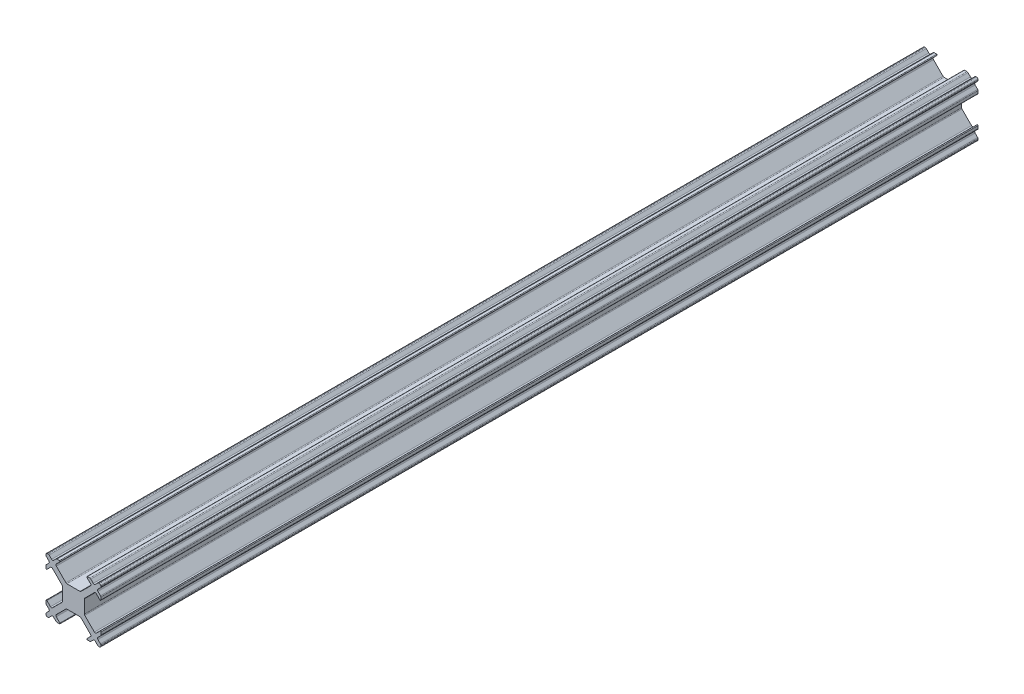
from build123d import *

# Parameters (mm, degrees)
BOSS_EXTRUDE1_DEPTH = 160


with BuildPart() as part:
    # Sketch1 → Boss-Extrude1 (new body)
    with BuildSketch(Plane.XY):
        with BuildLine():
            Line((-26.434620061, 28.496491655), (-25.979594809, 28.951516907))
            ThreePointArc((-25.979594809, 28.951516907), (-25.906371503, 29.128293603), (-25.979594808, 29.305070299))
            Line((-25.979594808, 29.305070299), (-26.43462006, 29.760095551))
            ThreePointArc((-26.43462006, 29.760095551), (-26.488813248, 29.841201388), (-26.507843365, 29.936872247))
            Line((-26.507843365, 29.936872247), (-26.507843365, 30.078293605))
            ThreePointArc((-26.507843365, 30.078293605), (-26.43462006, 30.255070299), (-26.257843366, 30.328293604))
            Line((-26.257843366, 30.328293604), (-26.11642201, 30.328293604))
            ThreePointArc((-26.11642201, 30.328293604), (-26.020751153, 30.309263487), (-25.939645316, 30.255070299))
            Line((-25.939645316, 30.255070299), (-25.484620061, 29.800045045))
            ThreePointArc((-25.484620061, 29.800045045), (-25.307843366, 29.72682174), (-25.131066671, 29.800045045))
            Line((-25.131066671, 29.800045045), (-24.676041418, 30.255070298))
            ThreePointArc((-24.676041418, 30.255070298), (-24.594935581, 30.309263487), (-24.499264722, 30.328293604))
            Line((-24.499264722, 30.328293604), (-24.042157942, 30.328293604))
            ThreePointArc((-24.042157942, 30.328293604), (-23.949769989, 30.266561947), (-23.971447265, 30.157582926))
            Line((-23.971447265, 30.157582926), (-24.623959891, 29.505070299))
            ThreePointArc((-24.623959891, 29.505070299), (-24.697183196, 29.328293604), (-24.623959891, 29.15151691))
            Line((-24.623959891, 29.15151691), (-22.873959891, 27.401516909))
            ThreePointArc((-22.873959891, 27.401516909), (-22.792854054, 27.347323722), (-22.697183196, 27.328293605))
            Line((-22.697183196, 27.328293605), (-20.318503539, 27.328293605))
            ThreePointArc((-20.318503539, 27.328293605), (-20.222832681, 27.347323722), (-20.141726844, 27.401516909))
            Line((-20.141726844, 27.401516909), (-18.391726844, 29.15151691))
            ThreePointArc((-18.391726844, 29.15151691), (-18.318503539, 29.328293604), (-18.391726844, 29.505070299))
            Line((-18.391726844, 29.505070299), (-19.04423947, 30.157582926))
            ThreePointArc((-19.04423947, 30.157582926), (-19.065916745, 30.266561947), (-18.973528793, 30.328293604))
            Line((-18.973528793, 30.328293604), (-18.516422013, 30.328293604))
            ThreePointArc((-18.516422013, 30.328293604), (-18.420751155, 30.309263487), (-18.339645319, 30.2550703))
            Line((-18.339645319, 30.2550703), (-17.884620064, 29.800045045))
            ThreePointArc((-17.884620064, 29.800045045), (-17.707843369, 29.72682174), (-17.531066674, 29.800045045))
            Line((-17.531066674, 29.800045045), (-17.07604142, 30.2550703))
            ThreePointArc((-17.07604142, 30.2550703), (-16.994935583, 30.309263487), (-16.899264725, 30.328293604))
            Line((-16.899264725, 30.328293604), (-16.75784337, 30.328293604))
            ThreePointArc((-16.75784337, 30.328293604), (-16.581066675, 30.255070299), (-16.507843371, 30.078293605))
            Line((-16.507843371, 30.078293605), (-16.507843371, 29.936872247))
            ThreePointArc((-16.507843371, 29.936872247), (-16.526873488, 29.841201389), (-16.581066675, 29.760095552))
            Line((-16.581066675, 29.760095552), (-17.036091927, 29.3050703))
            ThreePointArc((-17.036091927, 29.3050703), (-17.109315232, 29.128293603), (-17.036091926, 28.951516907))
            Line((-17.036091926, 28.951516907), (-16.581066674, 28.496491655))
            ThreePointArc((-16.581066674, 28.496491655), (-16.526873486, 28.415385818), (-16.507843369, 28.31971496))
            Line((-16.507843369, 28.31971496), (-16.507843369, 27.862608178))
            ThreePointArc((-16.507843369, 27.862608178), (-16.569575025, 27.770220231), (-16.678554041, 27.791897499))
            Line((-16.678554041, 27.791897499), (-17.331066668, 28.444410126))
            ThreePointArc((-17.331066668, 28.444410126), (-17.507843364, 28.517633431), (-17.68462006, 28.444410125))
            Line((-17.68462006, 28.444410125), (-19.434620061, 26.694410125))
            ThreePointArc((-19.434620061, 26.694410125), (-19.488813248, 26.613304288), (-19.507843364, 26.51763343))
            Line((-19.507843364, 26.51763343), (-19.507843364, 24.138953775))
            ThreePointArc((-19.507843364, 24.138953775), (-19.488813247, 24.043282917), (-19.434620059, 23.962177079))
            Line((-19.434620059, 23.962177079), (-17.684620059, 22.212177079))
            ThreePointArc((-17.684620059, 22.212177079), (-17.507843363, 22.138953773), (-17.331066666, 22.212177077))
            Line((-17.331066666, 22.212177077), (-16.67855404, 22.864689704))
            ThreePointArc((-16.67855404, 22.864689704), (-16.569575019, 22.886366979), (-16.507843363, 22.793979027))
            Line((-16.507843363, 22.793979027), (-16.507843363, 22.336872245))
            ThreePointArc((-16.507843363, 22.336872245), (-16.52687348, 22.241201387), (-16.581066668, 22.16009555))
            Line((-16.581066668, 22.16009555), (-17.036091921, 21.705070296))
            ThreePointArc((-17.036091921, 21.705070296), (-17.109315225, 21.528293601), (-17.036091921, 21.351516906))
            Line((-17.036091921, 21.351516906), (-16.581066669, 20.896491654))
            ThreePointArc((-16.581066669, 20.896491654), (-16.526873481, 20.815385817), (-16.507843364, 20.719714959))
            Line((-16.507843364, 20.719714959), (-16.507843364, 20.578293601))
            ThreePointArc((-16.507843364, 20.578293601), (-16.581066669, 20.401516906), (-16.757843364, 20.328293601))
            Line((-16.757843364, 20.328293601), (-16.89926472, 20.328293601))
            ThreePointArc((-16.89926472, 20.328293601), (-16.994935578, 20.347323718), (-17.076041415, 20.401516905))
            Line((-17.076041415, 20.401516905), (-17.53106667, 20.85654216))
            ThreePointArc((-17.53106667, 20.85654216), (-17.707843365, 20.929765464), (-17.88462006, 20.85654216))
            Line((-17.88462006, 20.85654216), (-18.339645314, 20.401516905))
            ThreePointArc((-18.339645314, 20.401516905), (-18.420751151, 20.347323718), (-18.516422009, 20.328293601))
            Line((-18.516422009, 20.328293601), (-18.973528789, 20.328293601))
            ThreePointArc((-18.973528789, 20.328293601), (-19.065916743, 20.390025258), (-19.044239468, 20.499004281))
            Line((-19.044239468, 20.499004281), (-18.391726841, 21.151516907))
            ThreePointArc((-18.391726841, 21.151516907), (-18.318503536, 21.328293602), (-18.391726841, 21.505070297))
            Line((-18.391726841, 21.505070297), (-20.141726841, 23.255070297))
            ThreePointArc((-20.141726841, 23.255070297), (-20.222832678, 23.309263485), (-20.318503536, 23.328293602))
            Line((-20.318503536, 23.328293602), (-22.697183193, 23.328293602))
            ThreePointArc((-22.697183193, 23.328293602), (-22.792854051, 23.309263485), (-22.873959889, 23.255070297))
            Line((-22.873959889, 23.255070297), (-24.623959889, 21.505070297))
            ThreePointArc((-24.623959889, 21.505070297), (-24.697183193, 21.328293602), (-24.623959889, 21.151516907))
            Line((-24.623959889, 21.151516907), (-23.971447262, 20.499004281))
            ThreePointArc((-23.971447262, 20.499004281), (-23.949769986, 20.390025258), (-24.042157941, 20.328293601))
            Line((-24.042157941, 20.328293601), (-24.49926472, 20.328293601))
            ThreePointArc((-24.49926472, 20.328293601), (-24.594935579, 20.347323718), (-24.676041417, 20.401516907))
            Line((-24.676041417, 20.401516907), (-25.131066671, 20.85654216))
            ThreePointArc((-25.131066671, 20.85654216), (-25.307843365, 20.929765464), (-25.48462006, 20.85654216))
            Line((-25.48462006, 20.85654216), (-25.939645315, 20.401516906))
            ThreePointArc((-25.939645315, 20.401516906), (-26.020751152, 20.347323718), (-26.11642201, 20.328293601))
            Line((-26.11642201, 20.328293601), (-26.257843366, 20.328293601))
            ThreePointArc((-26.257843366, 20.328293601), (-26.434620061, 20.401516906), (-26.507843366, 20.578293601))
            Line((-26.507843366, 20.578293601), (-26.507843366, 20.719714959))
            ThreePointArc((-26.507843366, 20.719714959), (-26.488813249, 20.815385817), (-26.434620061, 20.896491655))
            Line((-26.434620061, 20.896491655), (-25.979594809, 21.351516907))
            ThreePointArc((-25.979594809, 21.351516907), (-25.906371505, 21.528293602), (-25.979594809, 21.705070297))
            Line((-25.979594809, 21.705070297), (-26.434620063, 22.16009555))
            ThreePointArc((-26.434620063, 22.16009555), (-26.48881325, 22.241201387), (-26.507843367, 22.336872245))
            Line((-26.507843367, 22.336872245), (-26.507843367, 22.793979027))
            ThreePointArc((-26.507843367, 22.793979027), (-26.446111711, 22.88636698), (-26.337132691, 22.864689705))
            Line((-26.337132691, 22.864689705), (-25.684620064, 22.212177078))
            ThreePointArc((-25.684620064, 22.212177078), (-25.507843369, 22.138953774), (-25.331066674, 22.212177078))
            Line((-25.331066674, 22.212177078), (-23.581066674, 23.962177078))
            ThreePointArc((-23.581066674, 23.962177078), (-23.526873485, 24.043282916), (-23.507843368, 24.138953775))
            Line((-23.507843368, 24.138953775), (-23.507843368, 26.51763343))
            ThreePointArc((-23.507843368, 26.51763343), (-23.526873484, 26.613304288), (-23.581066672, 26.694410125))
            Line((-23.581066672, 26.694410125), (-25.331066672, 28.444410125))
            ThreePointArc((-25.331066672, 28.444410125), (-25.507843367, 28.51763343), (-25.684620062, 28.444410125))
            Line((-25.684620062, 28.444410125), (-26.337132689, 27.791897498))
            ThreePointArc((-26.337132689, 27.791897498), (-26.44611171, 27.770220225), (-26.507843366, 27.862608178))
            Line((-26.507843366, 27.862608178), (-26.507843366, 28.31971496))
            ThreePointArc((-26.507843366, 28.31971496), (-26.488813249, 28.415385818), (-26.434620061, 28.496491655))
        make_face()
    extrude(amount=BOSS_EXTRUDE1_DEPTH)


solid = part.part
